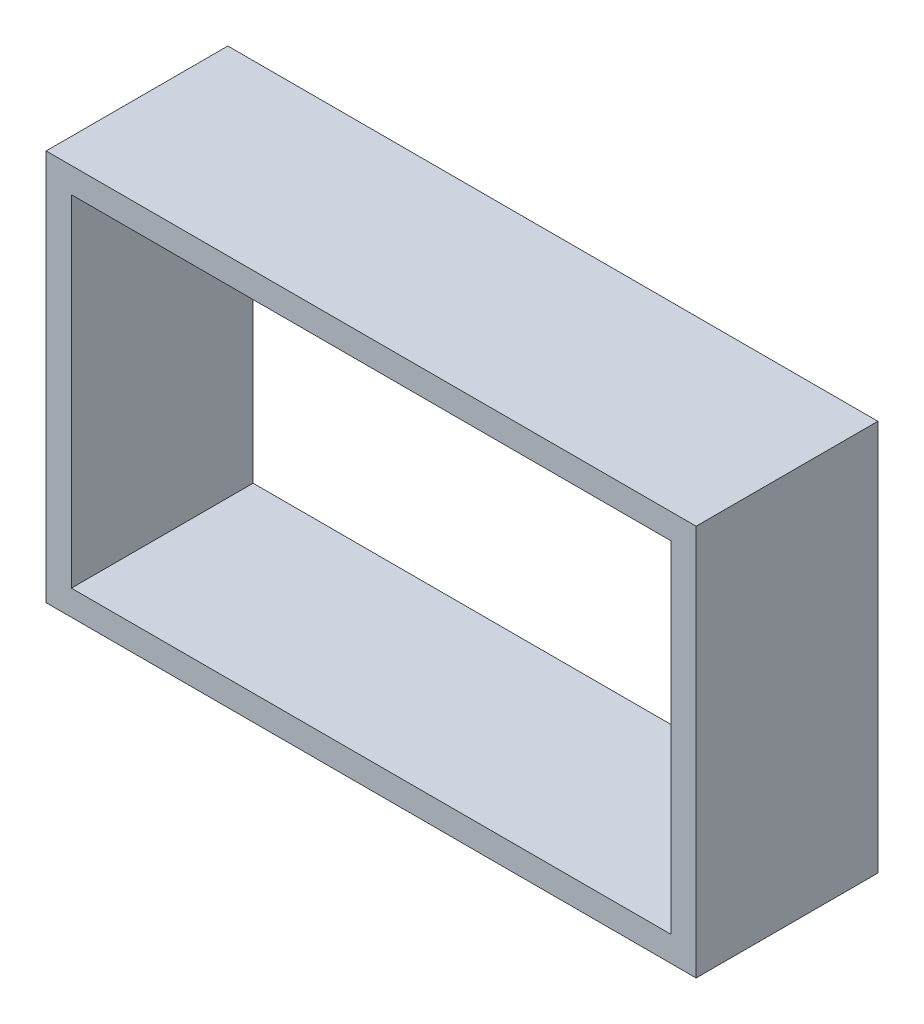
from build123d import *

# Parameters (mm, degrees)
CROQUIS1_W              = 51.5
CROQUIS1_H              = 31
CROQUIS1_W_2            = 47.5
CROQUIS1_H_2            = 27
SALIENTE_EXTRUIR1_DEPTH = 14.4


with BuildPart() as part:
    # Croquis1 → Saliente-Extruir1 (new body)
    with BuildSketch(Plane.XY):
        with Locations((-47.984383695, 4.515625)):
            Rectangle(CROQUIS1_W, CROQUIS1_H)
        with Locations((-47.984383695, 4.515625)):
            Rectangle(CROQUIS1_W_2, CROQUIS1_H_2, mode=Mode.SUBTRACT)
    extrude(amount=SALIENTE_EXTRUIR1_DEPTH)


solid = part.part
